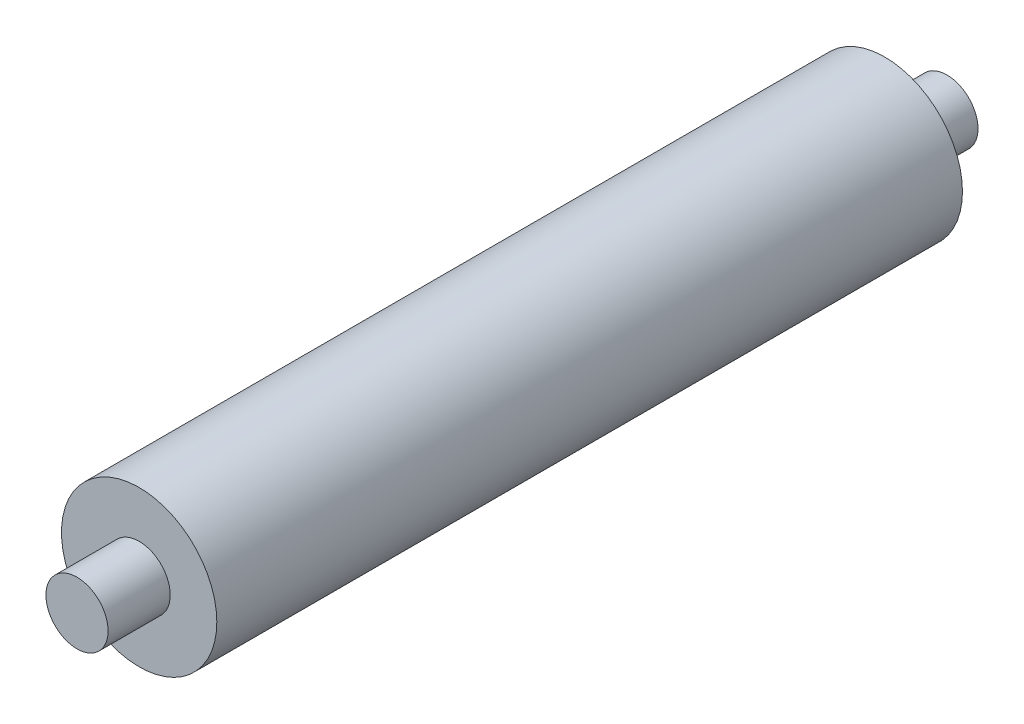
from build123d import *

# Parameters (mm, degrees)
SKETCH2_R           = 12.5
BOSS_EXTRUDE1_DEPTH = 120
SKETCH3_R           = 5
BOSS_EXTRUDE2_DEPTH = 10


with BuildPart() as part:
    # Sketch2 → Boss-Extrude1 (new body)
    with BuildSketch(Plane.XY):
        Circle(SKETCH2_R)
    extrude(amount=-BOSS_EXTRUDE1_DEPTH)

    # Sketch3 → Boss-Extrude2 (add)
    with BuildSketch(Plane.XY):
        Circle(SKETCH3_R)
    boss_extrude2 = extrude(amount=BOSS_EXTRUDE2_DEPTH)

    # Mirror1: Boss-Extrude2 across plane
    add(boss_extrude2.mirror(Plane.XY.offset(-60)))


solid = part.part
